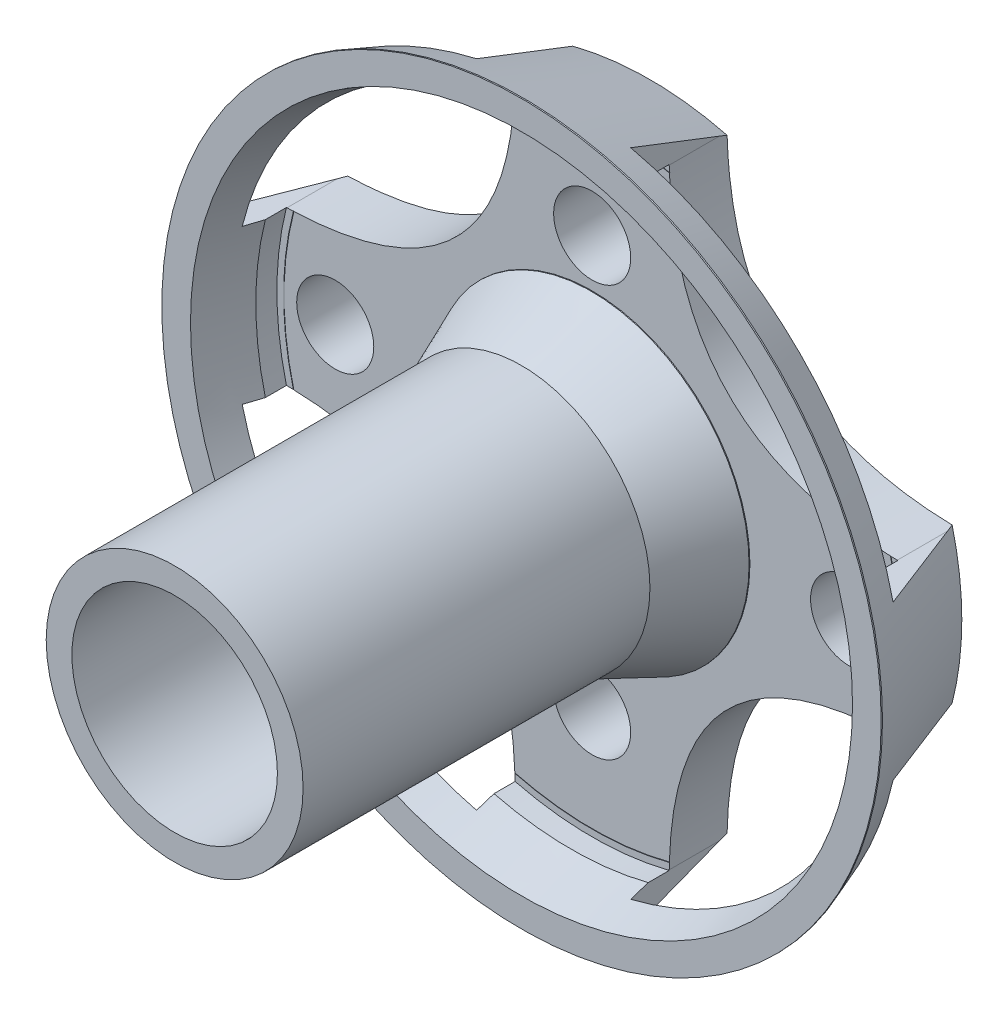
from build123d import *

# Parameters (mm, degrees)
SKETCH1_R           = 14
BOSS_EXTRUDE1_DEPTH = 18.5
SKETCH2_R           = 14
SKETCH2_R_2         = 5
CUT_EXTRUDE1_DEPTH  = 13.5
SKETCH3_R           = 4
CUT_EXTRUDE2_DEPTH  = 22.5
CUT_EXTRUDE3_DEPTH  = 3.75
SKETCH8_R           = 12.271364757
SKETCH8_R_2         = 6.141449245
CUT_EXTRUDE4_DEPTH  = 2.75
CIRPATTERN1_COUNT   = 4
SKETCH11_R          = 1.5
CUT_EXTRUDE5_DEPTH  = 3


with BuildPart() as part:
    # Sketch1 → Boss-Extrude1 (new body)
    with BuildSketch(Plane.XY):
        Circle(SKETCH1_R)
    extrude(amount=BOSS_EXTRUDE1_DEPTH)

    # Sketch2 → Cut-Extrude1 (cut)
    with BuildSketch(Plane.XY.offset(18.5)):
        Circle(SKETCH2_R)
        Circle(SKETCH2_R_2, mode=Mode.SUBTRACT)
    extrude(amount=-CUT_EXTRUDE1_DEPTH, mode=Mode.SUBTRACT)

    # Sketch3 → Cut-Extrude2 (cut)
    with BuildSketch(Plane.XY.offset(18.5)):
        Circle(SKETCH3_R)
    extrude(amount=-CUT_EXTRUDE2_DEPTH, mode=Mode.SUBTRACT)

    # Sketch6 → Cut-Revolve1 (revolve, cut)
    with BuildSketch(Plane(origin=(0, 0, 0), x_dir=(0, 0, -1), z_dir=(1, 0, 0))):
        Polygon((-4.949121361, 14), (3.777639186, 16.199586118), (5.061522468, 10.233304984), align=None)
    revolve(axis=Axis((0, 0, 19.921792725), (0, 0, -1)), mode=Mode.SUBTRACT)

    # Sketch7 → Cut-Extrude3 (cut)
    with BuildSketch(Plane(origin=(0, 0, 0), x_dir=(-1, 0, 0), z_dir=(0, 0, -1))):
        with BuildLine():
            Line((3, 15.639460569), (3, 11.87697352))
            add(Edge.make_bspline(
                [(3, 11.87697352), (3.121054504, 3.206614769), (11.87697352, 3)],
                knots=[0, 0, 0, 1, 1, 1], degree=2))
            Line((11.87697352, 3), (17.86108213, 3))
            Line((17.86108213, 3), (14.869027825, 14.316513241))
            Line((14.869027825, 14.316513241), (3, 15.639460569))
        make_face()
    cut_extrude3 = extrude(amount=-CUT_EXTRUDE3_DEPTH, mode=Mode.SUBTRACT)

    # Sketch8 → Cut-Extrude4 (cut)
    with BuildSketch(Plane.XY.offset(5)):
        Circle(SKETCH8_R)
        Circle(SKETCH8_R_2, mode=Mode.SUBTRACT)
    extrude(amount=-CUT_EXTRUDE4_DEPTH, mode=Mode.SUBTRACT)

    # Sketch9 → Cut-Revolve2 (revolve, cut)
    with BuildSketch(Plane(origin=(0, 0, 0), x_dir=(1, 0, 0), z_dir=(0, 1, 0))):
        Polygon((-12.001476603, -2.22152714), (-13.001507243, -5.36905248), (-11.155114973, -5.36905248), align=None)
    revolve(axis=Axis((0, 0, -1.742471472), (0, 0, 1)), mode=Mode.SUBTRACT)

    # Sketch10 → Cut-Revolve3 (revolve, cut)
    with BuildSketch(Plane(origin=(0, 0, 0), x_dir=(1, 0, 0), z_dir=(0, 1, 0))):
        Polygon((-5, -5), (-6.141449245, -2.28305418), (-6.572257958, -5.413209842), align=None)
    revolve(axis=Axis((0, 0, 0), (0, 0, -1)), mode=Mode.SUBTRACT)

    # CirPattern1: Cut-Extrude3 ×4 about axis
    cirpattern1_axis = Axis((0, 0, 3.75), (0, 0, 1))
    for i in range(1, CIRPATTERN1_COUNT):
        add(cut_extrude3.rotate(cirpattern1_axis, i * 360 / CIRPATTERN1_COUNT), mode=Mode.SUBTRACT)

    # Sketch11 → Cut-Extrude5 (cut)
    with BuildSketch(Plane(origin=(0, 0, 0), x_dir=(-1, 0, 0), z_dir=(0, 0, -1))):
        with Locations((0, 8)):
            Circle(SKETCH11_R)
        with Locations((0, -8)):
            Circle(SKETCH11_R)
        with Locations((-10, 0)):
            Circle(SKETCH11_R)
        with Locations((10, 0)):
            Circle(SKETCH11_R)
    extrude(amount=-CUT_EXTRUDE5_DEPTH, mode=Mode.SUBTRACT)


solid = part.part
